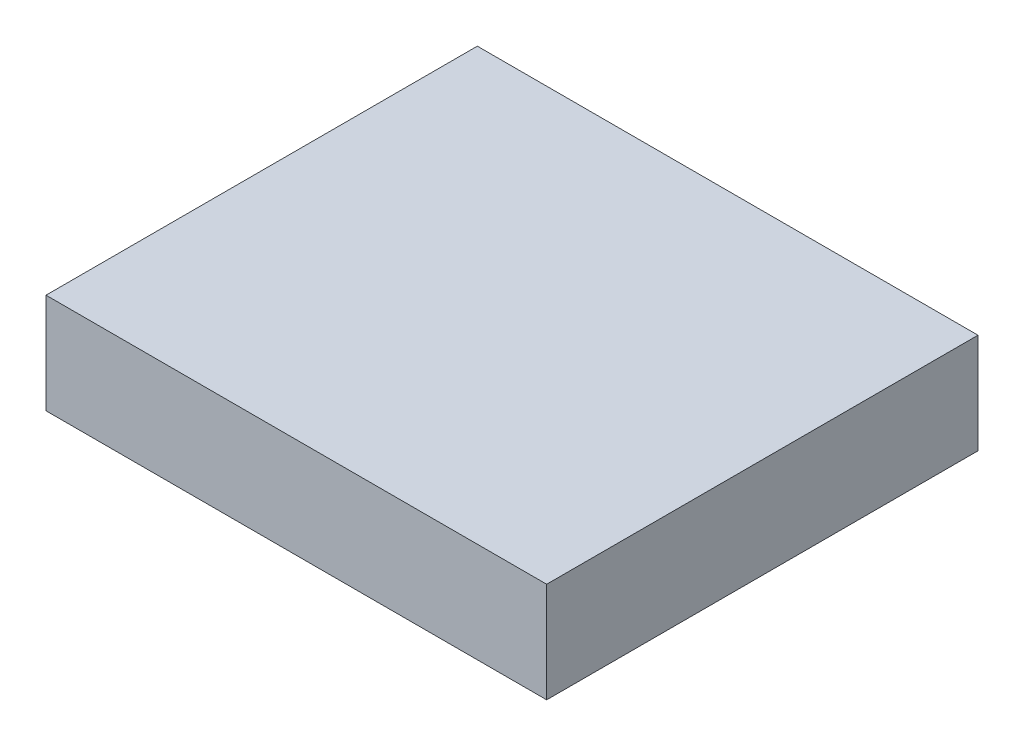
from build123d import *

# Parameters (mm, degrees)
SKETCH1_W           = 65
SKETCH1_H           = 56
BOSS_EXTRUDE1_DEPTH = 13


with BuildPart() as part:
    # Sketch1 → Boss-Extrude1 (new body)
    with BuildSketch(Plane(origin=(0, 0, 0), x_dir=(1, 0, 0), z_dir=(0, 1, 0))):
        with Locations((32.5, 28)):
            Rectangle(SKETCH1_W, SKETCH1_H)
    extrude(amount=BOSS_EXTRUDE1_DEPTH)


solid = part.part
